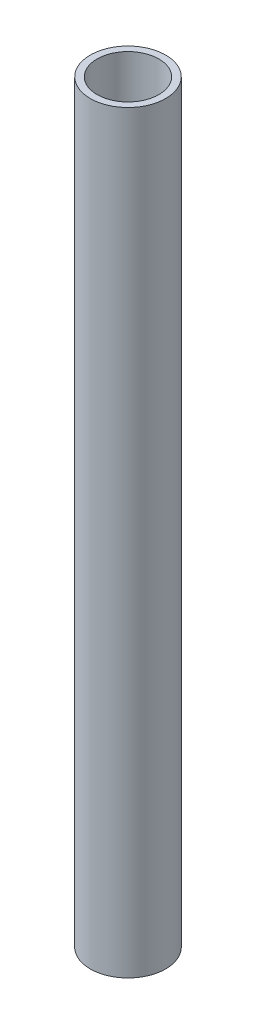
from build123d import *

# Parameters (mm, degrees)
SKETCH1_R           = 12.7
SKETCH1_R_2         = 10.414
BOSS_EXTRUDE1_DEPTH = 254


with BuildPart() as part:
    # Sketch1 → Boss-Extrude1 (new body)
    with BuildSketch(Plane(origin=(0, 0, 0), x_dir=(1, 0, 0), z_dir=(0, 1, 0))):
        Circle(SKETCH1_R)
        Circle(SKETCH1_R_2, mode=Mode.SUBTRACT)
    extrude(amount=BOSS_EXTRUDE1_DEPTH)


solid = part.part
